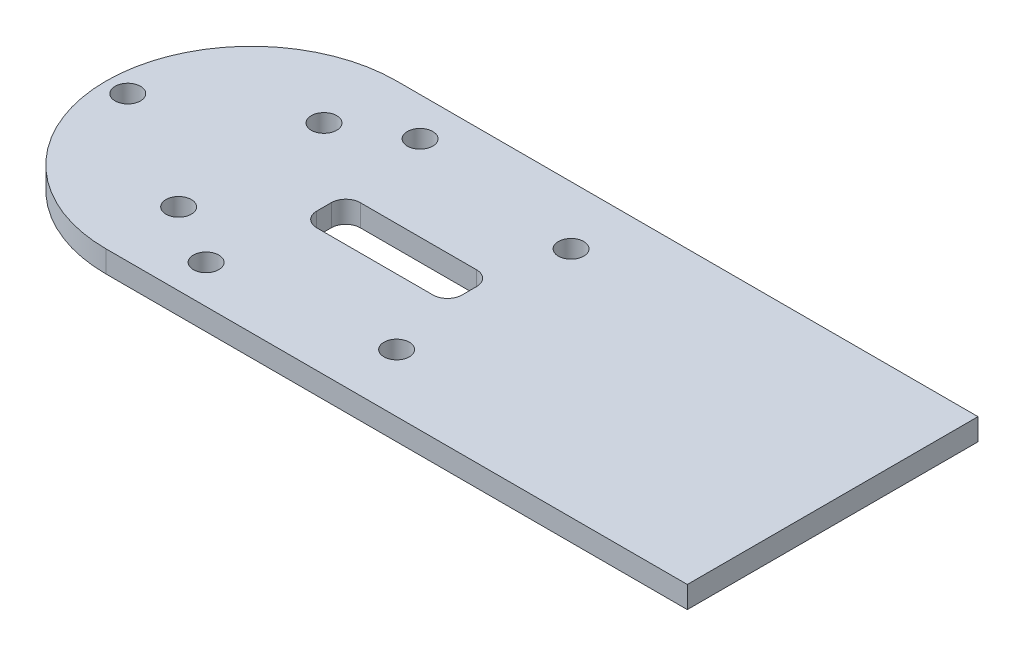
from build123d import *

# Parameters (mm, degrees)
BOSS_EXTRUDE1_DEPTH = 3
SKETCH3_R           = 1.75
CUT_EXTRUDE1_DEPTH  = 4
CUT_EXTRUDE2_REACH  = 5
SKETCH4_W           = 20
SKETCH4_H           = 6
FILLET1_R           = 2
CUT_EXTRUDE3_REACH  = 5
SKETCH5_R           = 1.75
CUT_EXTRUDE4_REACH  = 5
SKETCH7_R           = 1.75


with BuildPart() as part:
    # Sketch1 → Boss-Extrude1 (new body)
    with BuildSketch(Plane(origin=(0, 0, 0), x_dir=(1, 0, 0), z_dir=(0, 1, 0))):
        with BuildLine():
            Line((50, -20), (-30, -20))
            ThreePointArc((-30, -20), (-50, 0), (-30, 20))
            Line((-30, 20), (50, 20))
            Line((50, 20), (50, -20))
        make_face()
    extrude(amount=BOSS_EXTRUDE1_DEPTH)

    # Sketch3 → Cut-Extrude1 (cut, through all)
    with BuildSketch(Plane(origin=(0, 3, 0), x_dir=(1, 0, 0), z_dir=(0, 1, 0))):
        with Locations((-30, 10)):
            Circle(SKETCH3_R)
        with Locations((-30, -10)):
            Circle(SKETCH3_R)
    extrude(amount=-CUT_EXTRUDE1_DEPTH, mode=Mode.SUBTRACT)

    # Sketch4 → Cut-Extrude2 (cut, up to next)
    with BuildSketch(Plane.XZ, mode=Mode.PRIVATE) as cut_extrude2_sk1:
        with Locations((-10, 0)):
            Rectangle(SKETCH4_W, SKETCH4_H)
    cut_extrude2_tool1 = extrude(cut_extrude2_sk1.sketch, amount=-CUT_EXTRUDE2_REACH, mode=Mode.PRIVATE) & part.part
    add(cut_extrude2_tool1.solids().sort_by_distance((-10, 0, 0))[0], mode=Mode.SUBTRACT)

    # Fillet1
    fillet1_edges = [part.edges().sort_by_distance(p)[0] for p in [
        (-20, 1.5, -3),
        (-20, 1.5, 3),
        (0, 1.5, 3),
        (0, 1.5, -3),
    ]]
    fillet(fillet1_edges, radius=FILLET1_R)

    # Sketch5 → Cut-Extrude3 (cut, up to next)
    with BuildSketch(Plane.XZ, mode=Mode.PRIVATE) as cut_extrude3_sk1:
        with Locations((-21.5, -14.722431864)):
            Circle(SKETCH5_R)
    cut_extrude3_tool1 = extrude(cut_extrude3_sk1.sketch, amount=-CUT_EXTRUDE3_REACH, mode=Mode.PRIVATE) & part.part
    add(cut_extrude3_tool1.solids().sort_by_distance((-21.5, 0, -14.722432))[0], mode=Mode.SUBTRACT)
    # Sketch5 → Cut-Extrude3 (cut, up to next)
    with BuildSketch(Plane.XZ, mode=Mode.PRIVATE) as cut_extrude3_sk2:
        with Locations((-21.5, 14.722431864)):
            Circle(SKETCH5_R)
    cut_extrude3_tool2 = extrude(cut_extrude3_sk2.sketch, amount=-CUT_EXTRUDE3_REACH, mode=Mode.PRIVATE) & part.part
    add(cut_extrude3_tool2.solids().sort_by_distance((-21.5, 0, 14.722432))[0], mode=Mode.SUBTRACT)
    # Sketch5 → Cut-Extrude3 (cut, up to next)
    with BuildSketch(Plane.XZ, mode=Mode.PRIVATE) as cut_extrude3_sk3:
        with Locations((-47, 0)):
            Circle(SKETCH5_R)
    cut_extrude3_tool3 = extrude(cut_extrude3_sk3.sketch, amount=-CUT_EXTRUDE3_REACH, mode=Mode.PRIVATE) & part.part
    add(cut_extrude3_tool3.solids().sort_by_distance((-47, 0, 0))[0], mode=Mode.SUBTRACT)

    # Sketch7 → Cut-Extrude4 (cut, up to next)
    with BuildSketch(Plane.XZ, mode=Mode.PRIVATE) as cut_extrude4_sk1:
        with Locations((2, 12)):
            Circle(SKETCH7_R)
    cut_extrude4_tool1 = extrude(cut_extrude4_sk1.sketch, amount=-CUT_EXTRUDE4_REACH, mode=Mode.PRIVATE) & part.part
    add(cut_extrude4_tool1.solids().sort_by_distance((2, 0, 12))[0], mode=Mode.SUBTRACT)
    # Sketch7 → Cut-Extrude4 (cut, up to next)
    with BuildSketch(Plane.XZ, mode=Mode.PRIVATE) as cut_extrude4_sk2:
        with Locations((2, -12)):
            Circle(SKETCH7_R)
    cut_extrude4_tool2 = extrude(cut_extrude4_sk2.sketch, amount=-CUT_EXTRUDE4_REACH, mode=Mode.PRIVATE) & part.part
    add(cut_extrude4_tool2.solids().sort_by_distance((2, 0, -12))[0], mode=Mode.SUBTRACT)


solid = part.part
